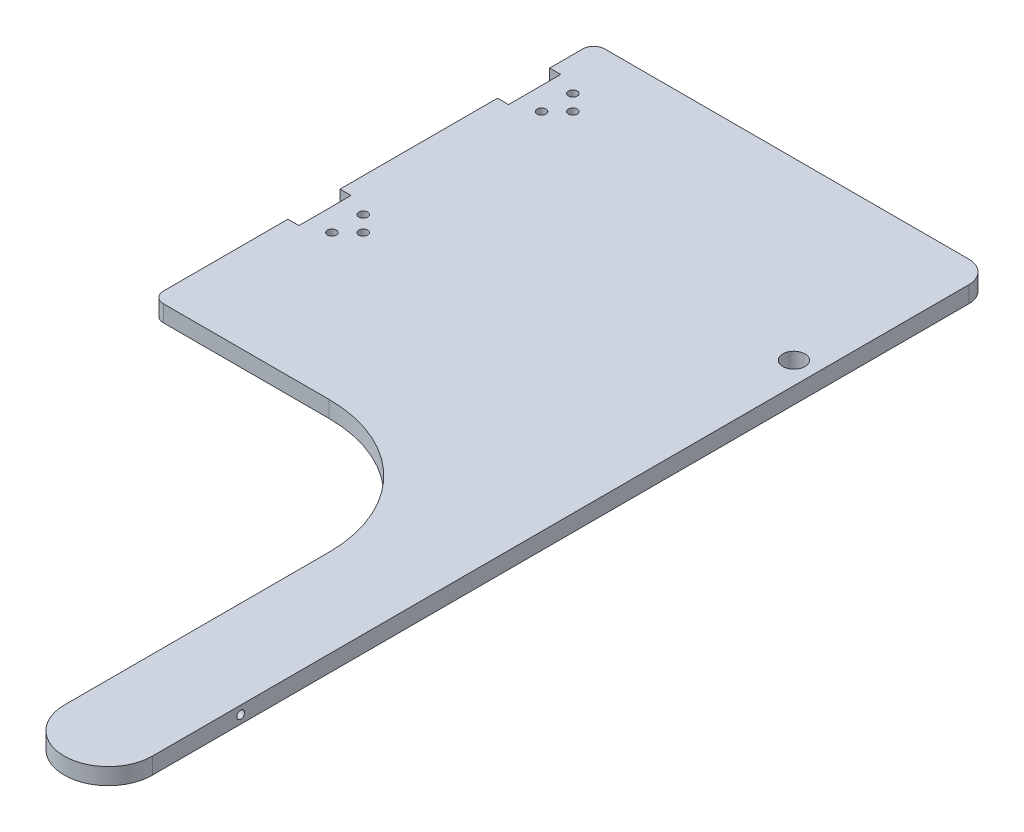
from build123d import *

# Parameters (mm, degrees)
BOSS_EXTRUDE1_DEPTH            = 9.525
CUT_EXTRUDE1_REACH             = 11.525
SKETCH2_R                      = 2.54
SKETCH2_W                      = 6.35
SKETCH2_H                      = 30
CUT_EXTRUDE2_REACH             = 230.6
SKETCH3_R                      = 2.2479
F_7_0_201_DIAMETER_HOLE1_D     = 5.1054
F_7_0_201_DIAMETER_HOLE1_DEPTH = 3.175
F_7_0_201_DIAMETER_HOLE1_TIP   = 1.533816902
SKETCH7_R                      = 6.35
CUT_EXTRUDE3_DEPTH             = 10.525


with BuildPart() as part:
    # Sketch1 → Boss-Extrude1 (new body)
    with BuildSketch(Plane(origin=(0, 0, 0), x_dir=(1, 0, 0), z_dir=(0, 1, 0))):
        with BuildLine():
            Line((6.35, 0), (101.6, 0))
            ThreePointArc((101.6, 0), (155.481536726, -22.318463274), (177.8, -76.2))
            Line((177.8, -76.2), (177.8, -228.6))
            ThreePointArc((177.8, -228.6), (203.2, -254), (228.6, -228.6))
            Line((228.6, -228.6), (228.6, 241.3))
            ThreePointArc((228.6, 241.3), (224.880256121, 250.280256121), (215.9, 254))
            Line((215.9, 254), (6.35, 254))
            ThreePointArc((6.35, 254), (1.859871939, 252.140128061), (0, 247.65))
            Line((0, 247.65), (0, 6.35))
            ThreePointArc((0, 6.35), (1.859871939, 1.859871939), (6.35, 0))
        make_face()
    extrude(amount=BOSS_EXTRUDE1_DEPTH)

    # Sketch2 → Cut-Extrude1 (cut, up to next)
    with BuildSketch(Plane(origin=(0, 9.525, 0), x_dir=(1, 0, 0), z_dir=(0, 1, 0)), mode=Mode.PRIVATE) as cut_extrude1_sk1:
        with Locations((28.34999918, 213.6)):
            Circle(SKETCH2_R)
    cut_extrude1_tool1 = extrude(cut_extrude1_sk1.sketch, amount=-CUT_EXTRUDE1_REACH, mode=Mode.PRIVATE) & part.part
    add(cut_extrude1_tool1.solids().sort_by_distance((28.349999, 9.525, -213.6))[0], mode=Mode.SUBTRACT)
    # Sketch2 → Cut-Extrude1 (cut, up to next)
    with BuildSketch(Plane(origin=(0, 9.525, 0), x_dir=(1, 0, 0), z_dir=(0, 1, 0)), mode=Mode.PRIVATE) as cut_extrude1_sk2:
        with Locations((19.3499994, 222.59999978)):
            Circle(SKETCH2_R)
    cut_extrude1_tool2 = extrude(cut_extrude1_sk2.sketch, amount=-CUT_EXTRUDE1_REACH, mode=Mode.PRIVATE) & part.part
    add(cut_extrude1_tool2.solids().sort_by_distance((19.349999, 9.525, -222.6))[0], mode=Mode.SUBTRACT)
    # Sketch2 → Cut-Extrude1 (cut, up to next)
    with BuildSketch(Plane(origin=(0, 9.525, 0), x_dir=(1, 0, 0), z_dir=(0, 1, 0)), mode=Mode.PRIVATE) as cut_extrude1_sk3:
        with Locations((19.3499994, 204.60000022)):
            Circle(SKETCH2_R)
    cut_extrude1_tool3 = extrude(cut_extrude1_sk3.sketch, amount=-CUT_EXTRUDE1_REACH, mode=Mode.PRIVATE) & part.part
    add(cut_extrude1_tool3.solids().sort_by_distance((19.349999, 9.525, -204.6))[0], mode=Mode.SUBTRACT)
    # Sketch2 → Cut-Extrude1 (cut, up to next)
    with BuildSketch(Plane(origin=(0, 9.525, 0), x_dir=(1, 0, 0), z_dir=(0, 1, 0)), mode=Mode.PRIVATE) as cut_extrude1_sk4:
        with Locations((28.34999918, 92.95)):
            Circle(SKETCH2_R)
    cut_extrude1_tool4 = extrude(cut_extrude1_sk4.sketch, amount=-CUT_EXTRUDE1_REACH, mode=Mode.PRIVATE) & part.part
    add(cut_extrude1_tool4.solids().sort_by_distance((28.349999, 9.525, -92.95))[0], mode=Mode.SUBTRACT)
    # Sketch2 → Cut-Extrude1 (cut, up to next)
    with BuildSketch(Plane(origin=(0, 9.525, 0), x_dir=(1, 0, 0), z_dir=(0, 1, 0)), mode=Mode.PRIVATE) as cut_extrude1_sk5:
        with Locations((19.3499994, 101.94999978)):
            Circle(SKETCH2_R)
    cut_extrude1_tool5 = extrude(cut_extrude1_sk5.sketch, amount=-CUT_EXTRUDE1_REACH, mode=Mode.PRIVATE) & part.part
    add(cut_extrude1_tool5.solids().sort_by_distance((19.349999, 9.525, -101.95))[0], mode=Mode.SUBTRACT)
    # Sketch2 → Cut-Extrude1 (cut, up to next)
    with BuildSketch(Plane(origin=(0, 9.525, 0), x_dir=(1, 0, 0), z_dir=(0, 1, 0)), mode=Mode.PRIVATE) as cut_extrude1_sk6:
        with Locations((19.3499994, 83.95000022)):
            Circle(SKETCH2_R)
    cut_extrude1_tool6 = extrude(cut_extrude1_sk6.sketch, amount=-CUT_EXTRUDE1_REACH, mode=Mode.PRIVATE) & part.part
    add(cut_extrude1_tool6.solids().sort_by_distance((19.349999, 9.525, -83.95))[0], mode=Mode.SUBTRACT)
    # Sketch2 → Cut-Extrude1 (cut, up to next)
    with BuildSketch(Plane(origin=(0, 9.525, 0), x_dir=(1, 0, 0), z_dir=(0, 1, 0)), mode=Mode.PRIVATE) as cut_extrude1_sk7:
        with Locations((3.175, 213.6)):
            Rectangle(SKETCH2_W, SKETCH2_H)
    cut_extrude1_tool7 = extrude(cut_extrude1_sk7.sketch, amount=-CUT_EXTRUDE1_REACH, mode=Mode.PRIVATE) & part.part
    add(cut_extrude1_tool7.solids().sort_by_distance((3.175, 9.525, -213.6))[0], mode=Mode.SUBTRACT)
    # Sketch2 → Cut-Extrude1 (cut, up to next)
    with BuildSketch(Plane(origin=(0, 9.525, 0), x_dir=(1, 0, 0), z_dir=(0, 1, 0)), mode=Mode.PRIVATE) as cut_extrude1_sk8:
        with Locations((3.175, 92.95)):
            Rectangle(SKETCH2_W, SKETCH2_H)
    cut_extrude1_tool8 = extrude(cut_extrude1_sk8.sketch, amount=-CUT_EXTRUDE1_REACH, mode=Mode.PRIVATE) & part.part
    add(cut_extrude1_tool8.solids().sort_by_distance((3.175, 9.525, -92.95))[0], mode=Mode.SUBTRACT)

    # Sketch3 → Cut-Extrude2 (cut, up to next)
    with BuildSketch(Plane(origin=(228.6, 0, 0), x_dir=(0, 0, -1), z_dir=(1, 0, 0)), mode=Mode.PRIVATE) as cut_extrude2_sk1:
        with Locations((-177.8, 4.7625)):
            Circle(SKETCH3_R)
    cut_extrude2_tool1 = extrude(cut_extrude2_sk1.sketch, amount=-CUT_EXTRUDE2_REACH, mode=Mode.PRIVATE) & part.part
    add(cut_extrude2_tool1.solids().sort_by_distance((228.6, 4.7625, 177.8))[0], mode=Mode.SUBTRACT)

    # #7 (0.201) Diameter Hole1
    with Locations(Plane(origin=(0, 0, 0), x_dir=(-1, 0, 0), z_dir=(0, -1, 0))):
        with Locations((-165.1, 143.75), (-165.1, 162.8)):
            Hole(F_7_0_201_DIAMETER_HOLE1_D / 2, depth=F_7_0_201_DIAMETER_HOLE1_DEPTH)
            with Locations((0, 0, -(F_7_0_201_DIAMETER_HOLE1_DEPTH + F_7_0_201_DIAMETER_HOLE1_TIP / 2))):  # 118° drill point
                Cone(0, F_7_0_201_DIAMETER_HOLE1_D / 2, F_7_0_201_DIAMETER_HOLE1_TIP, mode=Mode.SUBTRACT)

    # Sketch7 → Cut-Extrude3 (cut, through all)
    with BuildSketch(Plane(origin=(0, 9.525, 0), x_dir=(1, 0, 0), z_dir=(0, 1, 0))):
        with Locations((215.9, 153.275)):
            Circle(SKETCH7_R)
    extrude(amount=-CUT_EXTRUDE3_DEPTH, mode=Mode.SUBTRACT)


solid = part.part
